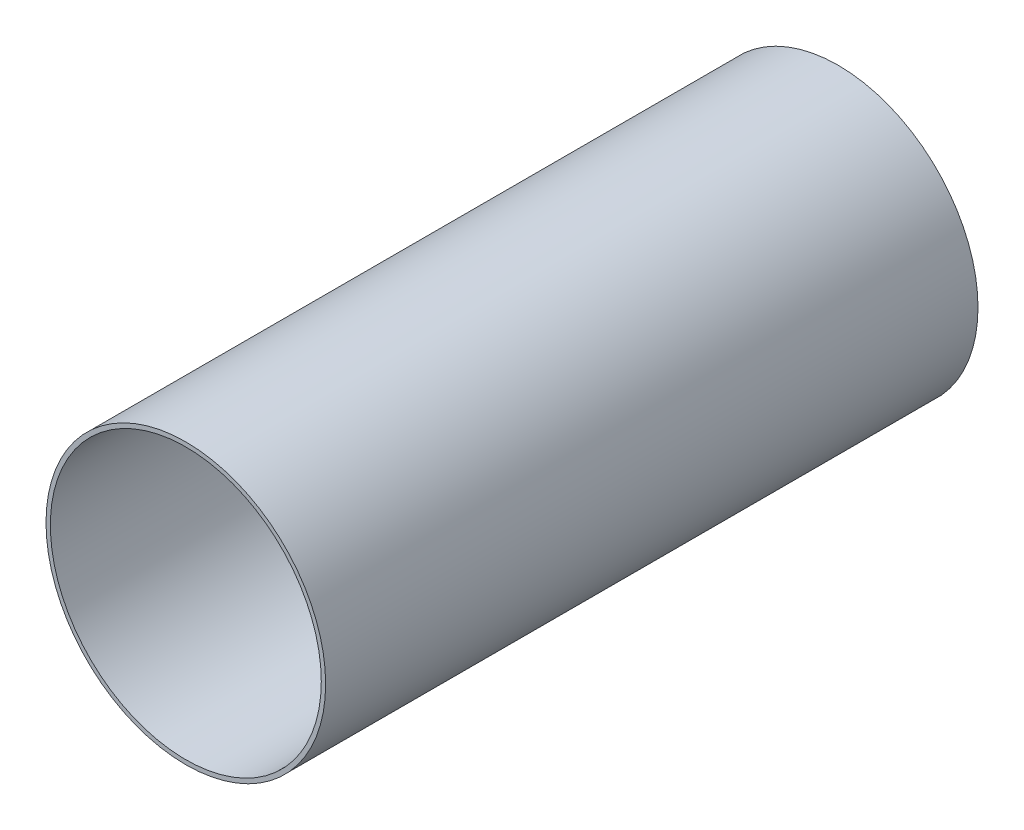
from build123d import *

# Parameters (mm, degrees)
SKETCH_1_R      = 643
SKETCH_1_R_2    = 623
EXTRUDE_1_DEPTH = 3000


with BuildPart() as part:
    # Эскиз1 → Вытянуть1 (new body)
    with BuildSketch(Plane.XY):
        with Locations((689, 689)):
            Circle(SKETCH_1_R)
        with Locations((689, 689)):
            Circle(SKETCH_1_R_2, mode=Mode.SUBTRACT)
    extrude(amount=-EXTRUDE_1_DEPTH)


solid = part.part
